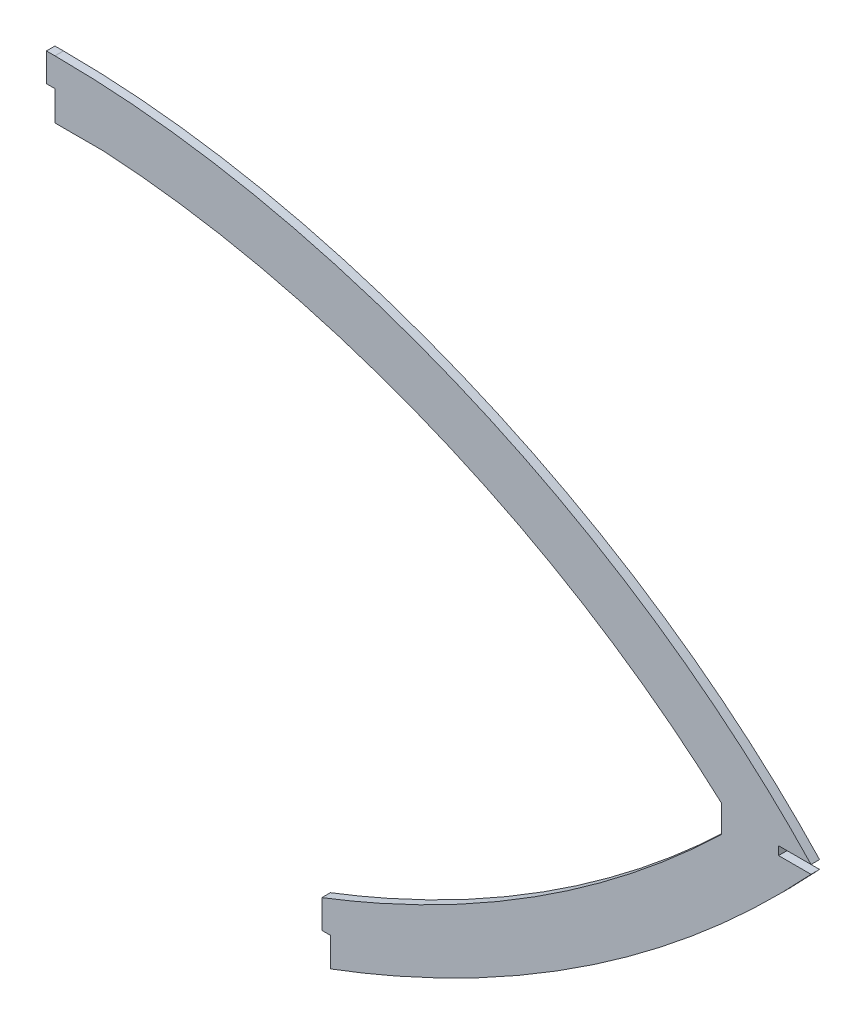
from build123d import *

# Parameters (mm, degrees)
BOSS_EXTRUDE1_DEPTH = 1.5


with BuildPart() as part:
    # Sketch1 → Boss-Extrude1 (new, symmetric)
    with BuildSketch(Plane.XY):
        with BuildLine():
            Line((162, 160.5), (159, 160.5))
            Line((159, 160.5), (159, 150.5))
            Line((159, 150.5), (162, 150.5))
            Line((162, 150.5), (162, 140.021619695))
            Line((162, 140.021619695), (179.035361639, 140.021619695))
            add(Edge.make_bspline(
                [(179.035361639, 140.021619695), (181.45177758, 139.887166151), (186.271210948, 139.563639144), (195.976712465, 138.692648533), (208.159899275, 137.190549701), (222.833276173, 134.736731876), (242.399897845, 130.612978325), (266.747664338, 123.892143887), (295.413182721, 113.431330715), (323.15664222, 100.694908753), (345.202971848, 88.292281007), (362.016251386, 77.366035054), (374.171038921, 68.686714489), (383.882043125, 61.067655319), (391.384292246, 54.745059633), (395.0336858, 51.518085922), (396.841652361, 49.879913246)],
                knots=[0.062605333, 0.062605333, 0.062605333, 0.062605333, 0.088988821, 0.115372309, 0.168139285, 0.220906261, 0.273673237, 0.379207188, 0.48474114, 0.590275092, 0.695809044, 0.74857602, 0.801342996, 0.854109972, 0.88049346, 0.906876948, 0.906876948, 0.906876948, 0.906876948], degree=3))
            Line((396.841652361, 49.879913246), (396.841652361, 40.472770569))
            add(Edge.make_bspline(
                [(396.841652361, 40.472770569), (394.239003506, 37.959600968), (388.961437182, 32.990250996), (378.229519379, 23.387370863), (364.429910112, 11.961116868), (347.266061507, -0.817277542), (329.48749774, -12.672358947), (311.087845987, -23.607837965), (292.061194965, -33.626734895), (275.670510367, -41.216070972), (263.560614549, -46.277800338), (258.079868533, -48.44047437), (255.999999882, -49.243263144)],
                knots=[0.498678358, 0.498678358, 0.498678358, 0.498678358, 0.498869027, 0.499059696, 0.499441034, 0.499822372, 0.50020371, 0.500585048, 0.500966386, 0.501347724, 0.501538394, 0.501654418, 0.501654418, 0.501654418, 0.501654418], degree=3))
            Line((255.999999882, -49.243263144), (256, -59.243263104))
            Line((256, -59.243263104), (259, -59.243263104))
            Line((259, -59.243263104), (259, -69.5))
            add(Edge.make_bspline(
                [(428.29663113, 44), (357.033753936, -32.746716062), (259, -69.5)],
                knots=[0, 0, 0, 1, 1, 1], degree=2))
            Line((428.29663113, 44), (416.841652361, 44))
            Line((416.841652361, 44), (416.841652361, 47))
            Line((416.841652361, 47), (428.287791795, 47.000000003))
            add(Edge.make_bspline(
                [(162, 160.5), (257.407389322, 160.5), (362.26969339, 117.467207351), (428.287791795, 47.000000003)],
                knots=[0, 0, 0, 0, 0.992973687, 0.992973687, 0.992973687, 0.992973687], degree=3))
        make_face()
    extrude(amount=BOSS_EXTRUDE1_DEPTH, both=True)


solid = part.part
